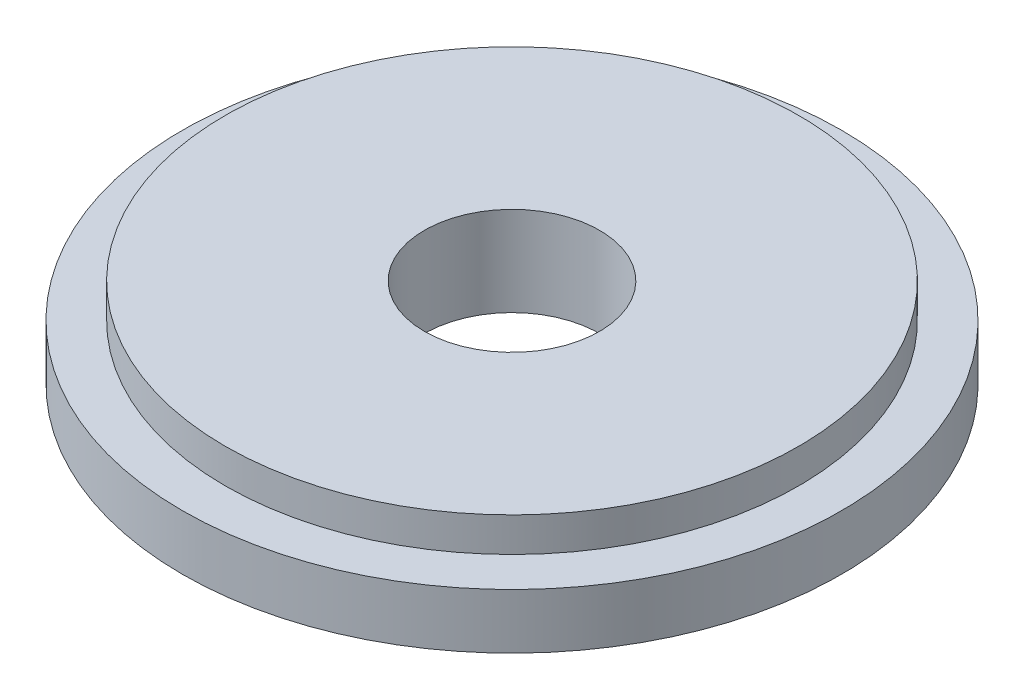
from build123d import *

# Parameters (mm, degrees)
SKETCH2_R           = 6.8326
BOSS_EXTRUDE1_DEPTH = 1.143
SKETCH3_R           = 5.9436
BOSS_EXTRUDE2_DEPTH = 0.7112
SKETCH4_R           = 1.8161
CUT_EXTRUDE1_DEPTH  = 2.8542


with BuildPart() as part:
    # Sketch2 → Boss-Extrude1 (new body)
    with BuildSketch(Plane(origin=(0, 0, 0), x_dir=(1, 0, 0), z_dir=(0, 1, 0))):
        Circle(SKETCH2_R)
    extrude(amount=BOSS_EXTRUDE1_DEPTH)

    # Sketch3 → Boss-Extrude2 (add)
    with BuildSketch(Plane(origin=(0, 1.143, 0), x_dir=(1, 0, 0), z_dir=(0, 1, 0))):
        Circle(SKETCH3_R)
    extrude(amount=BOSS_EXTRUDE2_DEPTH)

    # Sketch4 → Cut-Extrude1 (cut, through all)
    with BuildSketch(Plane(origin=(0, 1.8542, 0), x_dir=(1, 0, 0), z_dir=(0, 1, 0))):
        Circle(SKETCH4_R)
    extrude(amount=-CUT_EXTRUDE1_DEPTH, mode=Mode.SUBTRACT)


solid = part.part
